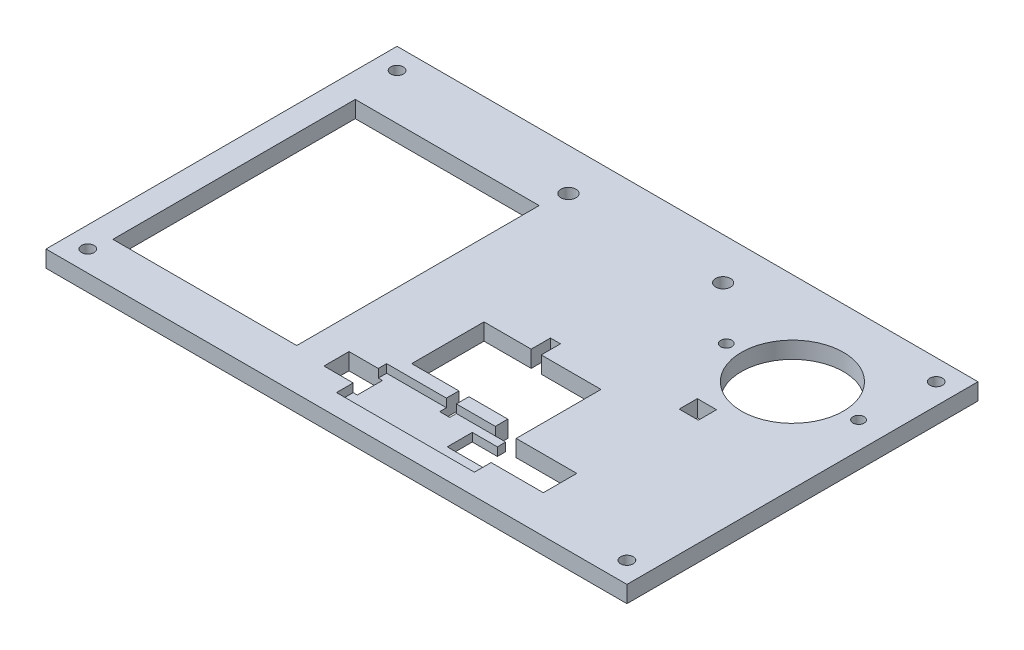
from build123d import *

# Parameters (mm, degrees)
BOSS_EXTRUDE1_DEPTH = 5.08
SKETCH3_R           = 1.905
CUT_EXTRUDE1_DEPTH  = 6.08
SKETCH4_R           = 1.905
SKETCH4_R_2         = 2.286
CUT_EXTRUDE2_DEPTH  = 6.08
CUT_EXTRUDE3_DEPTH  = 6.08
SKETCH6_R           = 15.494
SKETCH6_R_2         = 1.7
CUT_EXTRUDE4_DEPTH  = 6.08
SKETCH7_W           = 55.88
SKETCH7_H           = 73.66
CUT_EXTRUDE5_DEPTH  = 6.08
SKETCH8_W           = 5.838418679
SKETCH8_H           = 5.514062087
CUT_EXTRUDE6_DEPTH  = 6.08
CUT_EXTRUDE7_DEPTH  = 6.08
SKETCH12_W          = 10.16
SKETCH12_H          = 7.62
CUT_EXTRUDE8_DEPTH  = 6.08
SKETCH13_W          = 41.91
SKETCH13_H          = 15.24
CUT_EXTRUDE9_DEPTH  = 2.54


with BuildPart() as part:
    # Sketch1 → Boss-Extrude1 (new body)
    with BuildSketch(Plane(origin=(0, 0, 0), x_dir=(1, 0, 0), z_dir=(0, 1, 0))):
        Polygon((-15.621, -53.34), (15.621, -53.34), (88.265, -53.34), (88.265, 53.34), (-88.265, 53.34), (-88.265, -53.34), align=None)
    extrude(amount=BOSS_EXTRUDE1_DEPTH)

    # Sketch3 → Cut-Extrude1 (cut, through all)
    with BuildSketch(Plane(origin=(0, 5.08, 0), x_dir=(1, 0, 0), z_dir=(0, 1, 0))):
        with Locations((-81.915, 46.99)):
            Circle(SKETCH3_R)
    extrude(amount=-CUT_EXTRUDE1_DEPTH, mode=Mode.SUBTRACT)

    # Sketch4 → Cut-Extrude2 (cut, through all)
    with BuildSketch(Plane(origin=(0, 5.08, 0), x_dir=(1, 0, 0), z_dir=(0, 1, 0))):
        with Locations((81.915, 46.99)):
            Circle(SKETCH4_R)
        with Locations((-81.915, -46.99)):
            Circle(SKETCH4_R)
        with Locations((81.915, -46.99)):
            Circle(SKETCH4_R)
        with Locations((23.495, 40.64)):
            Circle(SKETCH4_R_2)
        with Locations((-23.495, 40.64)):
            Circle(SKETCH4_R_2)
    extrude(amount=-CUT_EXTRUDE2_DEPTH, mode=Mode.SUBTRACT)

    # Sketch5 → Cut-Extrude3 (cut, through all)
    with BuildSketch(Plane.XZ):
        Polygon((-2.54, 27.94), (-2.54, 5.969), (11.811, 5.969), (11.811, 0.127), (14.859, 0.127), (14.859, 5.969), (33.02, 5.969), (33.02, 29.21), (33.02, 31.75), (26.67, 31.75), (26.67, 27.94), (25.80916534, 27.94), (14.859, 27.94), (14.859, 33.782), (11.811, 33.782), (11.811, 27.94), align=None)
    extrude(amount=-CUT_EXTRUDE3_DEPTH, mode=Mode.SUBTRACT)

    # Sketch6 → Cut-Extrude4 (cut, through all)
    with BuildSketch(Plane(origin=(0, 5.08, 0), x_dir=(1, 0, 0), z_dir=(0, 1, 0))):
        with Locations((60.071, 25.146)):
            Circle(SKETCH6_R)
        with Locations((39.9778, 25.146)):
            Circle(SKETCH6_R_2)
        with Locations((80.1642, 25.146)):
            Circle(SKETCH6_R_2)
    extrude(amount=-CUT_EXTRUDE4_DEPTH, mode=Mode.SUBTRACT)

    # Sketch7 → Cut-Extrude5 (cut, through all)
    with BuildSketch(Plane(origin=(0, 5.08, 0), x_dir=(1, 0, 0), z_dir=(0, 1, 0))):
        with Locations((-52.705, -3.81)):
            Rectangle(SKETCH7_W, SKETCH7_H)
    extrude(amount=-CUT_EXTRUDE5_DEPTH, mode=Mode.SUBTRACT)

    # Sketch8 → Cut-Extrude6 (cut, through all)
    with BuildSketch(Plane(origin=(0, 5.08, 0), x_dir=(1, 0, 0), z_dir=(0, 1, 0))):
        with Locations((52.991758435, 3.486833379)):
            Rectangle(SKETCH8_W, SKETCH8_H)
    extrude(amount=-CUT_EXTRUDE6_DEPTH, mode=Mode.SUBTRACT)

    # Sketch11 → Cut-Extrude7 (cut, through all)
    with BuildSketch(Plane.XZ):
        Polygon((29.845, 31.75), (51.435, 31.75), (51.435, 41.91), (29.845, 41.91), (22.225, 41.91), (22.225, 34.29), (29.845, 34.29), align=None)
    extrude(amount=-CUT_EXTRUDE7_DEPTH, mode=Mode.SUBTRACT)

    # Sketch12 → Cut-Extrude8 (cut, through all)
    with BuildSketch(Plane.XZ):
        with Locations((-10.16, 38.1)):
            Rectangle(SKETCH12_W, SKETCH12_H)
    extrude(amount=-CUT_EXTRUDE8_DEPTH, mode=Mode.SUBTRACT)

    # Sketch13 → Cut-Extrude9 (cut)
    with BuildSketch(Plane(origin=(0, 5.08, 0), x_dir=(1, 0, 0), z_dir=(0, 1, 0))):
        with Locations((14.605, -39.37)):
            Rectangle(SKETCH13_W, SKETCH13_H)
    extrude(amount=-CUT_EXTRUDE9_DEPTH, mode=Mode.SUBTRACT)


solid = part.part
